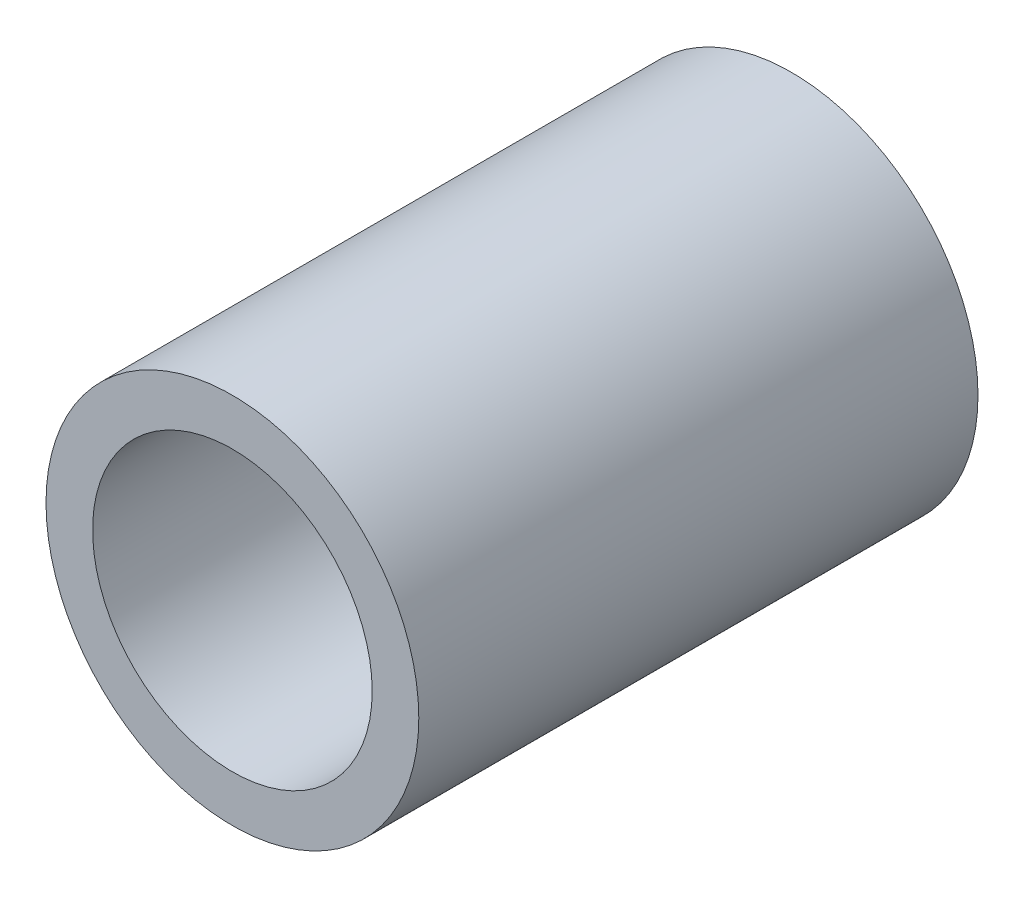
from build123d import *

# Parameters (mm, degrees)
SKETCH_1_R      = 8
SKETCH_1_R_2    = 6
EXTRUDE_1_DEPTH = 24


with BuildPart() as part:
    # Эскиз1 → Бобышка-Вытянуть1 (new body)
    with BuildSketch(Plane.XY):
        Circle(SKETCH_1_R)
        Circle(SKETCH_1_R_2, mode=Mode.SUBTRACT)
    extrude(amount=EXTRUDE_1_DEPTH)


solid = part.part
